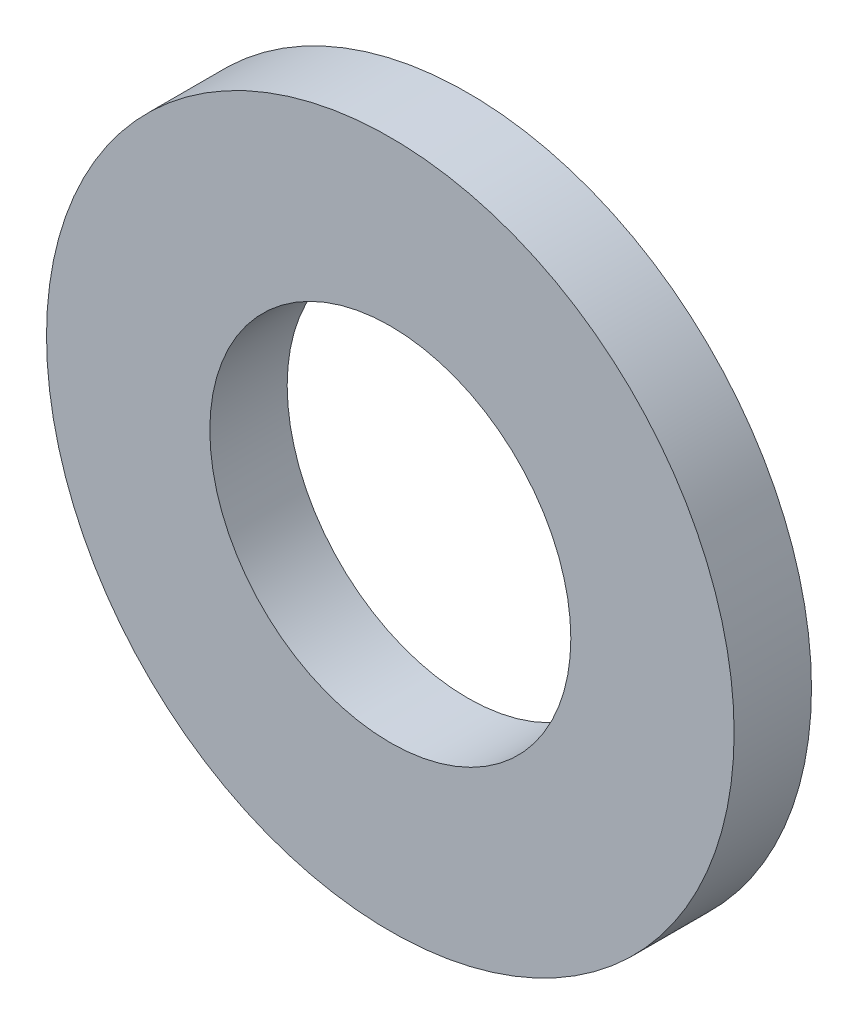
from build123d import *

# Parameters (mm, degrees)
SKETCH1_R         = 8
SKETCH1_R_2       = 4.2
WASHER_BOSS_DEPTH = 1.8


with BuildPart() as part:
    # Sketch1 → washer_boss (new body)
    with BuildSketch(Plane.XY):
        Circle(SKETCH1_R)
        Circle(SKETCH1_R_2, mode=Mode.SUBTRACT)
    extrude(amount=WASHER_BOSS_DEPTH)


solid = part.part
